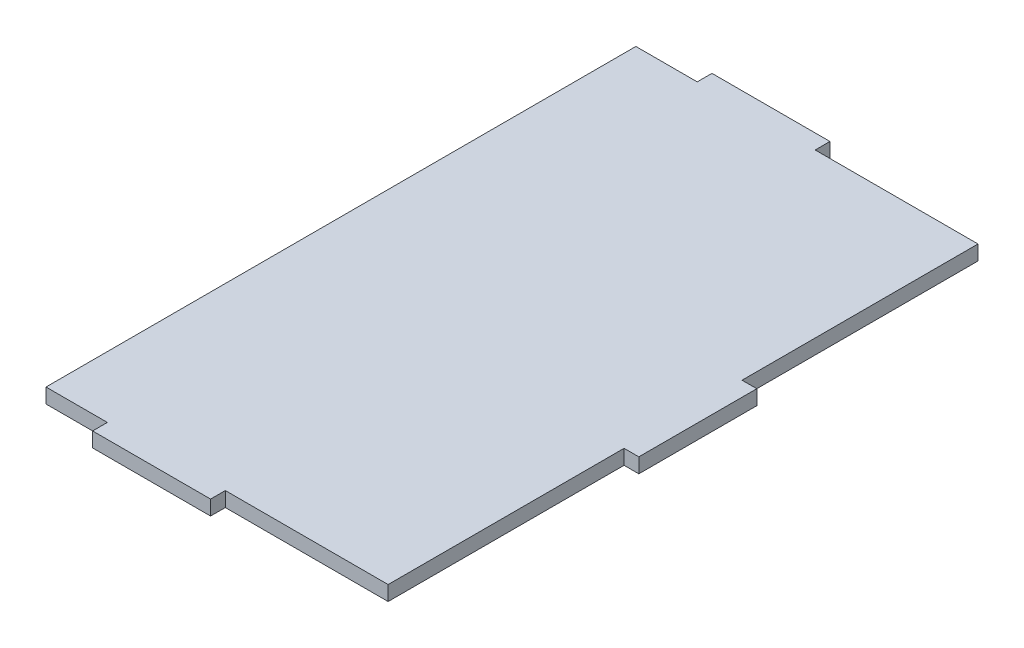
from build123d import *

# Parameters (mm, degrees)
SKETCH1_W           = 73.66
SKETCH1_H           = 127
BOSS_EXTRUDE1_DEPTH = 3.175
SKETCH2_W           = 25.4
SKETCH2_H           = 3.175
BOSS_EXTRUDE2_DEPTH = 3.175
SKETCH3_W           = 25.4
SKETCH3_H           = 3.175
BOSS_EXTRUDE3_DEPTH = 3.175
SKETCH5_W           = 25.4
SKETCH5_H           = 3.175
BOSS_EXTRUDE4_DEPTH = 3.175


with BuildPart() as part:
    # Sketch1 → Boss-Extrude1 (new body)
    with BuildSketch(Plane(origin=(0, 0, 0), x_dir=(1, 0, 0), z_dir=(0, 1, 0))):
        with Locations((38.311666667, 4.7625)):
            Rectangle(SKETCH1_W, SKETCH1_H)
    extrude(amount=BOSS_EXTRUDE1_DEPTH)

    # Sketch2 → Boss-Extrude2 (add)
    with BuildSketch(Plane(origin=(75.141666667, 0, 0), x_dir=(0, 0, -1), z_dir=(1, 0, 0))):
        with Locations((4.7625, 1.5875)):
            Rectangle(SKETCH2_W, SKETCH2_H)
    extrude(amount=BOSS_EXTRUDE2_DEPTH)

    # Sketch3 → Boss-Extrude3 (add)
    with BuildSketch(Plane.XY.offset(58.7375)):
        with Locations((27.389666667, 1.5875)):
            Rectangle(SKETCH3_W, SKETCH3_H)
    extrude(amount=BOSS_EXTRUDE3_DEPTH)

    # Sketch5 → Boss-Extrude4 (add)
    with BuildSketch(Plane(origin=(0, 0, -68.2625), x_dir=(-1, 0, 0), z_dir=(0, 0, -1))):
        with Locations((-27.389666667, 1.5875)):
            Rectangle(SKETCH5_W, SKETCH5_H)
    extrude(amount=BOSS_EXTRUDE4_DEPTH)


solid = part.part
